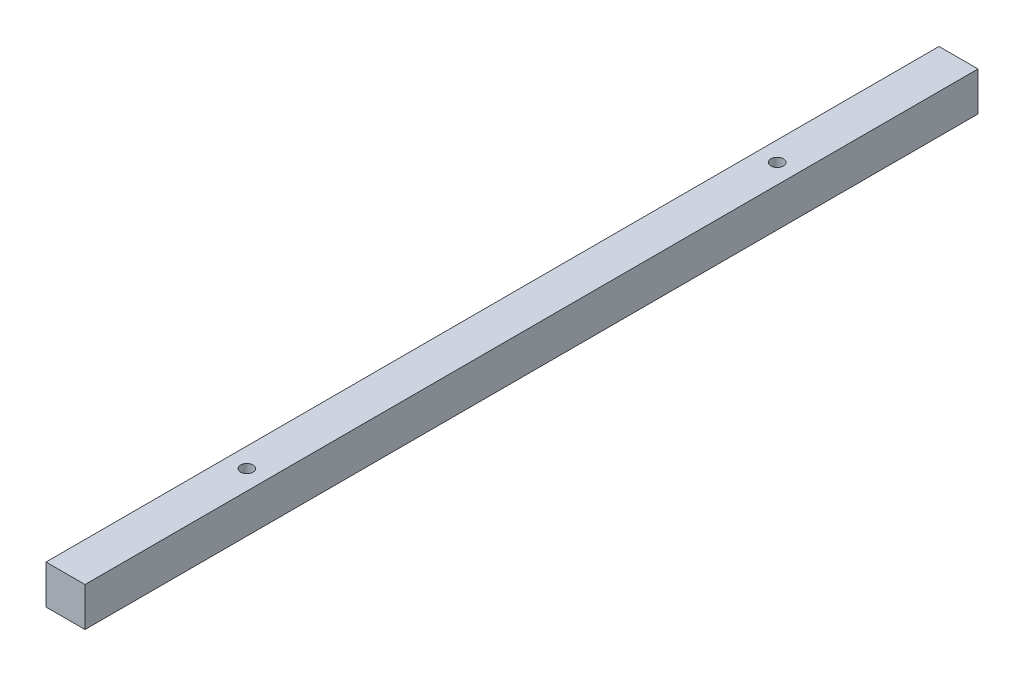
from build123d import *

# Parameters (mm, degrees)
ESQUISSE1_W             = 10
ESQUISSE1_H             = 10
BOSS_EXTRU_1_DEPTH      = 114.5
BOSS_EXTRU_1_DEPTH_BACK = 114.5
ESQUISSE2_R             = 1.6
ENL_V_MAT_EXTRU_1_DEPTH = 11


with BuildPart() as part:
    # Esquisse1 → Boss.-Extru.1 (new body, two sides)
    with BuildSketch(Plane.XY) as boss_extru_1_sk:
        Rectangle(ESQUISSE1_W, ESQUISSE1_H)
    extrude(amount=BOSS_EXTRU_1_DEPTH)
    extrude(boss_extru_1_sk.sketch, amount=-BOSS_EXTRU_1_DEPTH_BACK)

    # Esquisse2 → Enlèv. mat.-Extru.1 (cut, through all)
    with BuildSketch(Plane(origin=(0, 5, 0), x_dir=(1, 0, 0), z_dir=(0, 1, 0))):
        with Locations((0, 68)):
            Circle(ESQUISSE2_R)
        with Locations((0, -68)):
            Circle(ESQUISSE2_R)
    extrude(amount=-ENL_V_MAT_EXTRU_1_DEPTH, mode=Mode.SUBTRACT)


solid = part.part
